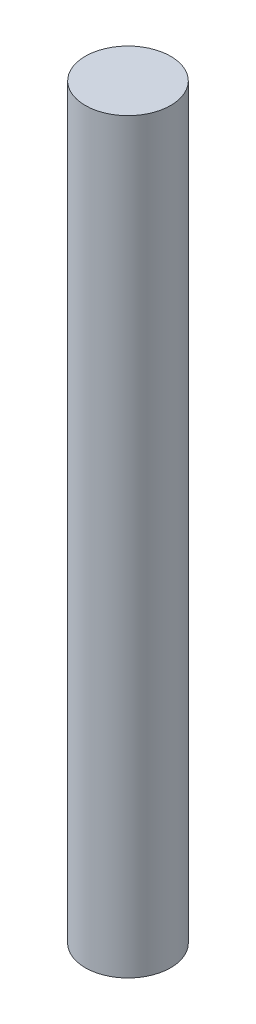
from build123d import *

# Parameters (mm, degrees)
SKETCH_1_R      = 4
EXTRUDE_1_DEPTH = 70


with BuildPart() as part:
    # 草图1 → 凸台-拉伸1 (new body)
    with BuildSketch(Plane(origin=(0, 0, 0), x_dir=(1, 0, 0), z_dir=(0, 1, 0))):
        Circle(SKETCH_1_R)
    extrude(amount=EXTRUDE_1_DEPTH)


solid = part.part
